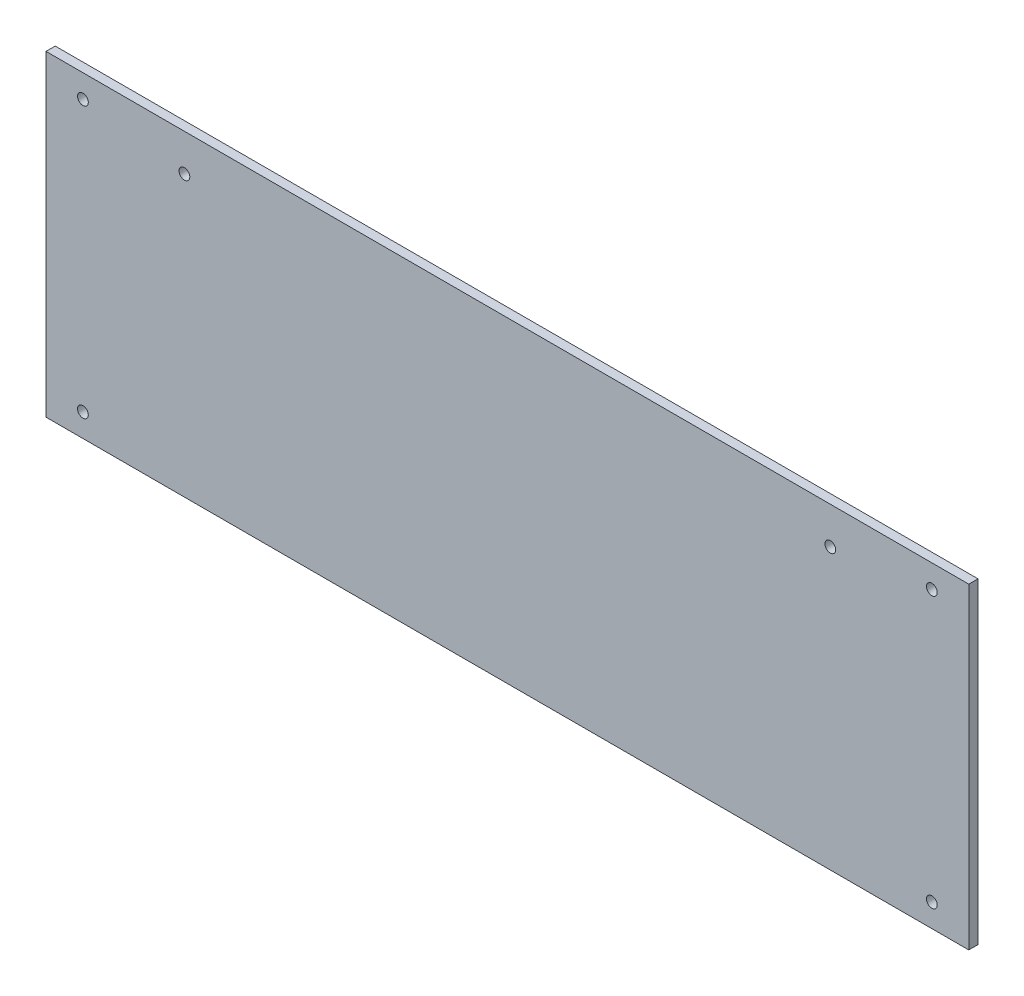
from build123d import *

# Parameters (mm, degrees)
SKETCH1_W           = 300
SKETCH1_H           = 103
SKETCH1_R           = 1.75
BOSS_EXTRUDE1_DEPTH = 3


with BuildPart() as part:
    # Sketch1 → Boss-Extrude1 (new body)
    with BuildSketch(Plane.XY.offset(3)):
        with Locations((150, 48.5)):
            Rectangle(SKETCH1_W, SKETCH1_H)
        with Locations((288, 92.5)):
            Circle(SKETCH1_R, mode=Mode.SUBTRACT)
        with Locations((12, 92.5)):
            Circle(SKETCH1_R, mode=Mode.SUBTRACT)
        with Locations((12, 4.5)):
            Circle(SKETCH1_R, mode=Mode.SUBTRACT)
        with Locations((288, 4.5)):
            Circle(SKETCH1_R, mode=Mode.SUBTRACT)
        with Locations((45, 88)):
            Circle(SKETCH1_R, mode=Mode.SUBTRACT)
        with Locations((255, 88)):
            Circle(SKETCH1_R, mode=Mode.SUBTRACT)
    extrude(amount=-BOSS_EXTRUDE1_DEPTH)


solid = part.part
